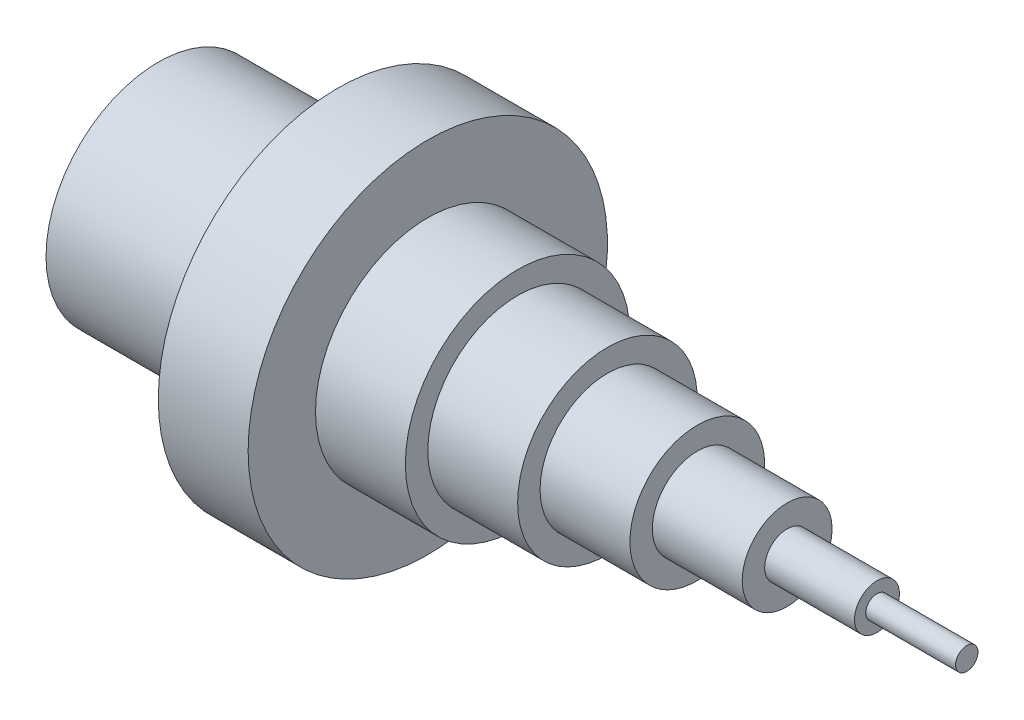
from build123d import *

# Parameters (mm, degrees)
SKETCH2_R          = 508
CUT_EXTRUDE2_DEPTH = 1016


with BuildPart() as part:
    # Sketch1 → Revolve1 (revolve)
    with BuildSketch(Plane.XY, mode=Mode.PRIVATE) as revolve1_sk:
        Polygon((0, 0), (0, -635), (1016, -635), (1016, -1016), (1524, -1016), (1524, -635), (2032, -635), (2032, -508), (2540, -508), (2540, -381), (3048, -381), (3048, -254), (3556, -254), (3556, -127), (4064, -127), (4064, -63.5), (4572, -63.5), (4572, 0), align=None)
    revolve(revolve1_sk.sketch.rotate(Axis((0, 0, 0), (1, 0, 0)), 270), axis=Axis((0, 0, 0), (1, 0, 0)))  # turned: the seam where the file's is

    # Sketch2 → Cut-Extrude2 (cut)
    with BuildSketch(Plane.ZY):
        Circle(SKETCH2_R)
    extrude(amount=-CUT_EXTRUDE2_DEPTH, mode=Mode.SUBTRACT)


solid = part.part
